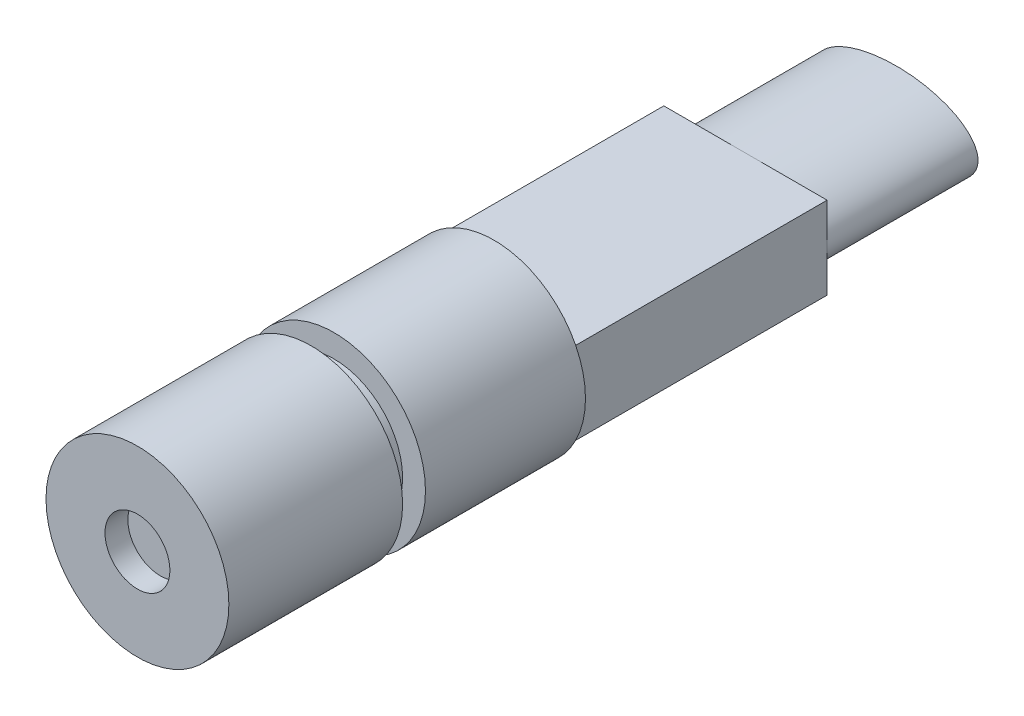
from build123d import *

# Parameters (mm, degrees)
SKETCH_1_R          = 2
EXTRUDE_1_DEPTH     = 7.8
CUT_EXTRUDE_START   = 3.5
SKETCH_2_R          = 2
SKETCH_2_R_2        = 1.5
CUT_EXTRUDE_1_DEPTH = 0.5
SKETCH_3_R          = 0.71
CUT_EXTRUDE_2_DEPTH = 0.5
SKETCH_4_W          = 3.57211422
SKETCH_4_H          = 1.8
EXTRUDE_2_DEPTH     = 5.5
SKETCH_5_RX         = 1.78605711
SKETCH_5_RY         = 0.9
EXTRUDE_3_DEPTH     = 3.3


with BuildPart() as part:
    # 草图1 → 凸台-拉伸1 (new body)
    with BuildSketch(Plane.XY):
        Circle(SKETCH_1_R)
    extrude(amount=EXTRUDE_1_DEPTH)

    # 草图2 → 切除-拉伸1 (cut)
    with BuildSketch(Plane.XY.offset(CUT_EXTRUDE_START)):
        Circle(SKETCH_2_R)
        Circle(SKETCH_2_R_2, mode=Mode.SUBTRACT)
    extrude(amount=CUT_EXTRUDE_1_DEPTH, mode=Mode.SUBTRACT)

    # 草图3 → 切除-拉伸2 (cut)
    with BuildSketch(Plane.XY.offset(7.8)):
        Circle(SKETCH_3_R)
    extrude(amount=-CUT_EXTRUDE_2_DEPTH, mode=Mode.SUBTRACT)

    # 草图4 → 凸台-拉伸2 (add)
    with BuildSketch(Plane.XY):
        Rectangle(SKETCH_4_W, SKETCH_4_H)
    extrude(amount=-EXTRUDE_2_DEPTH)

    # 草图5 → 凸台-拉伸3 (add)
    with BuildSketch(Plane(origin=(0, 0, -5.5), x_dir=(-1, 0, 0), z_dir=(0, 0, -1))):
        with Locations((0, 0)):
            Ellipse(SKETCH_5_RX, SKETCH_5_RY)
    extrude(amount=EXTRUDE_3_DEPTH)


solid = part.part
